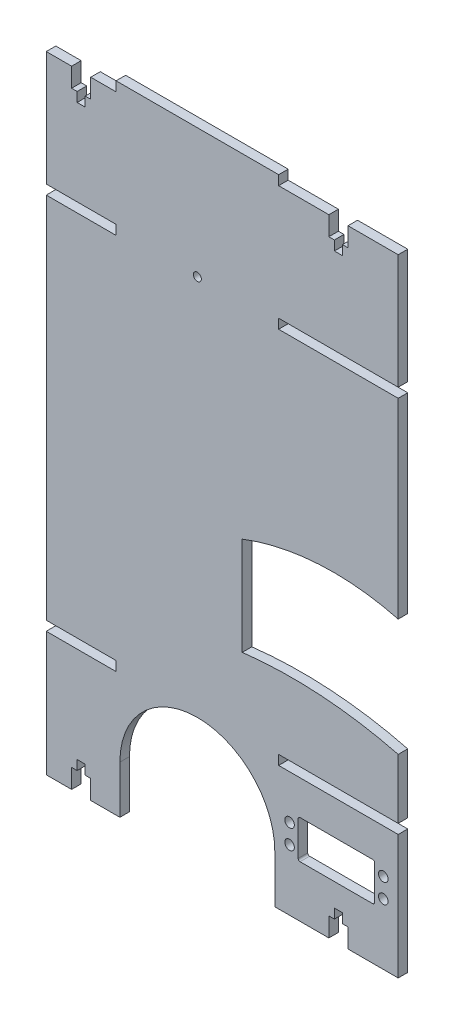
from build123d import *

# Parameters (mm, degrees)
SKETCH2_W               = 184
SKETCH2_H               = 332.5
BOSS_EXTRUDE1_DEPTH     = 5
SKETCH3_W               = 36.5
SKETCH3_H               = 5
SKETCH3_W_2             = 62.5
CUT_EXTRUDE1_DEPTH      = 5
CUT_EXTRUDE2_DEPTH      = 10
SKETCH5_R               = 2.1
CUT_EXTRUDE3_DEPTH      = 10
ESQUISSE1_R             = 2.5
ENL_V_MAT_EXTRU_1_DEPTH = 10
ENL_V_MAT_EXTRU_2_DEPTH = 10


with BuildPart() as part:
    # Sketch2 → Boss-Extrude1 (new body)
    with BuildSketch(Plane.XY):
        Rectangle(SKETCH2_W, SKETCH2_H)
    extrude(amount=BOSS_EXTRUDE1_DEPTH)

    # Sketch3 → Cut-Extrude1 (cut)
    with BuildSketch(Plane.XY.offset(5)):
        with Locations((-73.75, -98.75)):
            Rectangle(SKETCH3_W, SKETCH3_H)
        with Locations((60.75, -98.75)):
            Rectangle(SKETCH3_W_2, SKETCH3_H)
        with Locations((-73.75, 163.75)):
            Rectangle(SKETCH3_W, SKETCH3_H)
        with Locations((60.75, 163.75)):
            Rectangle(SKETCH3_W_2, SKETCH3_H)
        with Locations((60.75, 98.75)):
            Rectangle(SKETCH3_W_2, SKETCH3_H)
        with BuildLine():
            Line((27.5, -141.25), (27.5, -166.25))
            Line((27.5, -166.25), (-53.5, -166.25))
            Line((-53.5, -166.25), (-53.5, -141.25))
            ThreePointArc((-53.5, -141.25), (-13, -100.75), (27.5, -141.25))
        make_face()
        with Locations((-73.75, 98.75)):
            Rectangle(SKETCH3_W, SKETCH3_H)
    extrude(amount=-CUT_EXTRUDE1_DEPTH, mode=Mode.SUBTRACT)

    # Sketch4 → Cut-Extrude2 (cut)
    with BuildSketch(Plane.XY.offset(5)):
        Polygon((55.75, 161.25), (55.75, 151.25), (58.65, 151.25), (58.65, 146.25), (62.85, 146.25), (62.85, 151.25), (65.75, 151.25), (65.75, 161.25), align=None)
        Polygon((-78.75, 161.25), (-78.75, 151.25), (-75.85, 151.25), (-75.85, 146.25), (-71.65, 146.25), (-71.65, 151.25), (-68.75, 151.25), (-68.75, 161.25), align=None)
        Polygon((65.75, -166.25), (65.75, -156.25), (62.85, -156.25), (62.85, -151.25), (58.65, -151.25), (58.65, -156.25), (55.75, -156.25), (55.75, -166.25), align=None)
        Polygon((-68.75, -166.25), (-68.75, -156.25), (-71.65, -156.25), (-71.65, -151.25), (-75.85, -151.25), (-75.85, -156.25), (-78.75, -156.25), (-78.75, -166.25), align=None)
    extrude(amount=-CUT_EXTRUDE2_DEPTH, mode=Mode.SUBTRACT)

    # Sketch5 → Cut-Extrude3 (cut)
    with BuildSketch(Plane.XY.offset(5)):
        with Locations((-13, 98.75)):
            Circle(SKETCH5_R)
    extrude(amount=-CUT_EXTRUDE3_DEPTH, mode=Mode.SUBTRACT)

    # Esquisse1 → Enlèv. mat.-Extru.1 (cut)
    with BuildSketch(Plane(origin=(0, 0, 0), x_dir=(-1, 0, 0), z_dir=(0, 0, -1))):
        with Locations((-35.2, -134.33)):
            Circle(ESQUISSE1_R)
        with Locations((-35.2, -124.17)):
            Circle(ESQUISSE1_R)
        with Locations((-84.2, -134.33)):
            Circle(ESQUISSE1_R)
        with Locations((-84.2, -124.17)):
            Circle(ESQUISSE1_R)
        with BuildLine():
            Line((-40.7, -119.25), (-78.7, -119.25))
            ThreePointArc((-78.7, -119.25), (-79.407106781, -119.542893219), (-79.7, -120.25))
            Line((-79.7, -120.25), (-79.7, -138.25))
            ThreePointArc((-79.7, -138.25), (-79.407106781, -138.957106781), (-78.7, -139.25))
            Line((-78.7, -139.25), (-40.7, -139.25))
            ThreePointArc((-40.7, -139.25), (-39.992893219, -138.957106781), (-39.7, -138.25))
            Line((-39.7, -138.25), (-39.7, -120.25))
            ThreePointArc((-39.7, -120.25), (-39.992893219, -119.542893219), (-40.7, -119.25))
        make_face()
    extrude(amount=-ENL_V_MAT_EXTRU_1_DEPTH, mode=Mode.SUBTRACT)

    # Esquisse2 → Enlèv. mat.-Extru.2 (cut)
    with BuildSketch(Plane.XY.offset(5)):
        with BuildLine():
            Line((10.470660362, -8.273773364), (10.470660362, -59.567669296))
            ThreePointArc((10.470660362, -59.567669296), (51.484945295, -58.532619163), (92, -64.995841242))
            Line((92, -64.995841242), (92, -3.75037767))
            ThreePointArc((92, -3.75037767), (50.880784547, 0.378228003), (10.470660362, -8.273773364))
        make_face()
    extrude(amount=-ENL_V_MAT_EXTRU_2_DEPTH, mode=Mode.SUBTRACT)


solid = part.part
